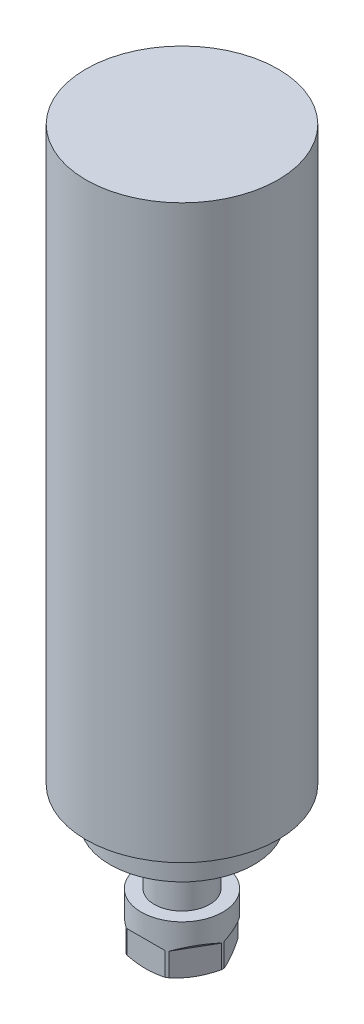
from build123d import *

# Parameters (mm, degrees)
CHAMFER2_SIZE       = 7
CHAMFER2_SIZE2      = 1.5
SKETCH2_R           = 11.5
BOSS_EXTRUDE1_DEPTH = 19
SKETCH3_R           = 17
BOSS_EXTRUDE2_DEPTH = 22.5
CHAMFER3_SIZE       = 2
CHAMFER3_SIZE2      = 4
CUT_EXTRUDE1_DEPTH  = 41
CIRPATTERN1_COUNT   = 6
SKETCH21_R          = 40
BOSS_EXTRUDE9_DEPTH = 238


with BuildPart() as part:
    # Sketch1 → Revolve1 (revolve)
    with BuildSketch(Plane(origin=(0, 0, 0), x_dir=(0, 0, -1), z_dir=(1, 0, 0))):
        Polygon((0, 128.3), (0, -128.3), (-24.1, -128.3), (-24.1, -123.7), (-30, -123.7), (-30, -109.7), (-39.9, -109.7), (-39.9, -99.7), (-40, -99.7), (-40, 100.3), (-39.9, 100.3), (-39.9, 128.3), align=None)
    revolve(axis=Axis((0, 128.3, 0), (0, -1, 0)))

    # Chamfer2
    chamfer2_edges = [part.edges().sort_by_distance(p)[0] for p in [
        (0, -128.3, -24.1),
    ]]
    chamfer2_side = [part.faces().sort_by_distance(p)[0] for p in [
        (0, -128.3, 0),
    ]]
    chamfer(chamfer2_edges, length=CHAMFER2_SIZE, length2=CHAMFER2_SIZE2, reference=chamfer2_side[0])

    # Sketch2 → Boss-Extrude1 (add)
    with BuildSketch(Plane.XZ.offset(128.3)):
        Circle(SKETCH2_R)
    extrude(amount=BOSS_EXTRUDE1_DEPTH)

    # Sketch3 → Boss-Extrude2 (add)
    with BuildSketch(Plane.XZ.offset(147.3)):
        Circle(SKETCH3_R)
    extrude(amount=BOSS_EXTRUDE2_DEPTH)

    # Chamfer3
    chamfer3_edges = [part.edges().sort_by_distance(p)[0] for p in [
        (-17, -169.8, 0),
    ]]
    chamfer3_side = [part.faces().sort_by_distance(p)[0] for p in [
        (-17, -158.55, 0),
    ]]
    chamfer(chamfer3_edges, length=CHAMFER3_SIZE, length2=CHAMFER3_SIZE2, reference=chamfer3_side[0])

    # Sketch7 → Cut-Extrude1 (cut, symmetric)
    with BuildSketch(Plane(origin=(0, 0, 0), x_dir=(0, 0, -1), z_dir=(1, 0, 0))):
        Polygon((-29.89327327, -143.30672673), (-15, -158.2), (-15, -177.081282463), (-29.89327327, -177.081282463), align=None)
    cut_extrude1 = extrude(amount=CUT_EXTRUDE1_DEPTH, both=True, mode=Mode.SUBTRACT)

    # CirPattern1: Cut-Extrude1 ×6 about axis
    cirpattern1_axis = Axis((0, 0, 0), (0, 1, 0))
    for i in range(1, CIRPATTERN1_COUNT):
        add(cut_extrude1.rotate(cirpattern1_axis, i * 360 / CIRPATTERN1_COUNT), mode=Mode.SUBTRACT)

    # Sketch21 → Boss-Extrude9 (add)
    with BuildSketch(Plane(origin=(0, 128.3, 0), x_dir=(1, 0, 0), z_dir=(0, 1, 0))):
        Circle(SKETCH21_R)
    extrude(amount=-BOSS_EXTRUDE9_DEPTH)


solid = part.part
